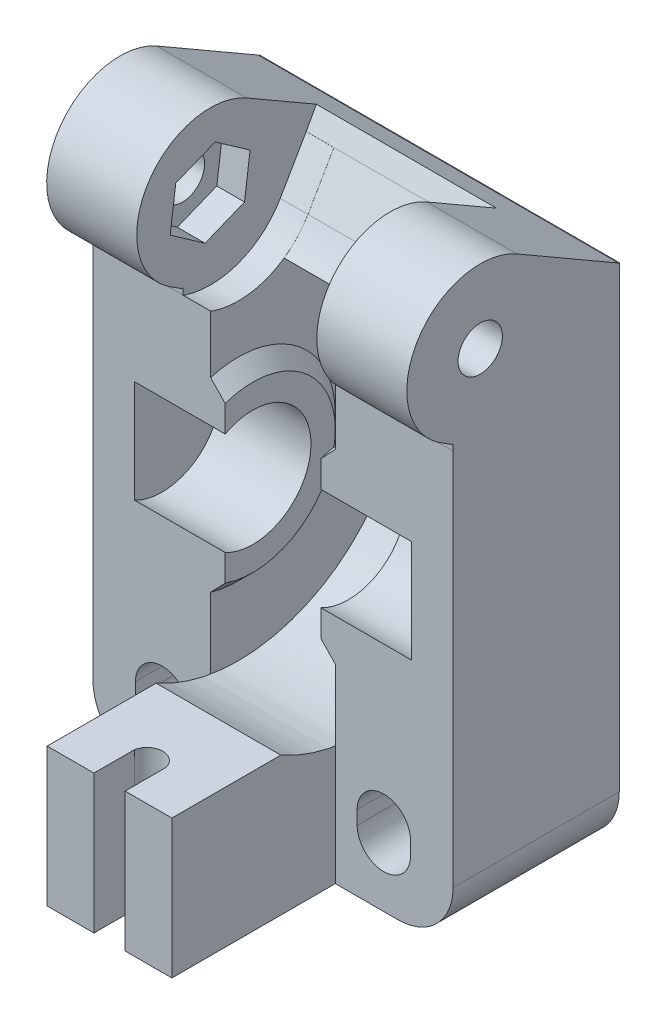
from build123d import *

# Parameters (mm, degrees)
BOSS_EXTRUDE1_DEPTH      = 4.5
BOSS_EXTRUDE2_DEPTH      = 8.5
BOSS_EXTRUDE6_DEPTH      = 6.5
BOSS_EXTRUDE4_DEPTH      = 1.05
BOSS_EXTRUDE8_REACH      = 49.945
CUT_EXTRUDE1_DEPTH       = 2
DRAFT1_ANGLE             = 44.789143365
M3_CLEARANCE_HOLE2_D     = 3.2
M8_CLEARANCE_HOLE1_D     = 8.407999997
M8_CLEARANCE_HOLE1_DEPTH = 6.549999998
BOSS_EXTRUDE5_DEPTH      = 4.5
CUT_EXTRUDE2_DEPTH       = 53.938496679
CUT_EXTRUDE3_DEPTH       = 35.848761309
FILLET1_R                = 4


with BuildPart() as part:
    # Sketch1 → Boss-Extrude1 (new body)
    with BuildSketch(Plane(origin=(-2, 0, 0), x_dir=(0, 0, -1), z_dir=(1, 0, 0))):
        with BuildLine():
            Line((-20.950248767, 5.007745307), (-22.824572843, 1.761345281))
            add(Edge.make_bspline(
                [(-22.824572843, 1.761345281), (-22.907235345, 1.63404528), (-22.989897847, 1.50674528), (-23.072560349, 1.379445279), (-23.090903988, 1.35119613), (-23.127591268, 1.294697832), (-23.187146413, 1.212723364), (-23.229540707, 1.160371306), (-23.250737854, 1.134195276), (-23.314414523, 1.055561942), (-23.378091191, 0.976928607), (-23.44176786, 0.898295272), (-23.462963255, 0.872121406), (-23.505354046, 0.819773673), (-23.573150965, 0.744483853), (-23.620785564, 0.696858132), (-23.644602863, 0.673045272), (-23.71614953, 0.60151194), (-23.787696196, 0.529978607), (-23.859242863, 0.458445275), (-23.883060949, 0.434631627), (-23.930697122, 0.387004333), (-24.005993759, 0.319211775), (-24.058341491, 0.276817446), (-24.084515357, 0.255620281), (-24.192798296, 0.167926271), (-24.301081235, 0.080232261), (-24.409364174, -0.007461749), (-24.415801672, -0.01267522), (-24.428676667, -0.023102162), (-24.448838233, -0.037748352), (-24.462734635, -0.046769251), (-24.469682836, -0.051279701), (-24.490556168, -0.0648297), (-24.511429499, -0.078379699), (-24.532302831, -0.091929698), (-24.535132328, -0.093766477), (-24.540791324, -0.097440034), (-24.537331747, -0.119297424), (-24.530814887, -0.121043793), (-24.527556458, -0.121916977), (-24.433502761, -0.147121213), (-24.339449064, -0.172325448), (-24.245395367, -0.197529683), (-24.221856021, -0.203837688), (-24.17477733, -0.216453699), (-24.105056076, -0.239110392), (-24.059554417, -0.25657939), (-24.036803587, -0.26531389), (-23.777816684, -0.364744152), (-23.51882978, -0.464174413), (-23.259842877, -0.563604675), (-23.19478657, -0.588581095), (-23.064673956, -0.638533935), (-22.87316776, -0.723799621), (-22.748984503, -0.787069656), (-22.686892875, -0.818704673), (-22.500366208, -0.913738006), (-22.31383954, -1.008771339), (-22.127312873, -1.103804671), (-22.065222187, -1.135439209), (-21.941040816, -1.198708283), (-21.75949603, -1.303520057), (-21.64261059, -1.379426466), (-21.584167871, -1.41737967), (-21.40859787, -1.531396336), (-21.233027869, -1.645413002), (-21.057457868, -1.759429668), (-20.999014093, -1.797383557), (-20.882126544, -1.873291336), (-20.712532127, -1.996511799), (-20.604220952, -2.084223711), (-20.550065365, -2.128079668), (-20.387373697, -2.259829668), (-20.224682029, -2.391579668), (-20.061990361, -2.523329668), (-20.007835687, -2.567184884), (-19.899526339, -2.654895317), (-19.743740529, -2.795161149), (-19.645187077, -2.893706834), (-19.595910351, -2.942979676), (-19.447882012, -3.090996348), (-19.299853674, -3.239013019), (-19.151825335, -3.387029691), (-19.102548454, -3.436302689), (-19.003994692, -3.534848683), (-18.8637252, -3.690633943), (-18.776019617, -3.798947782), (-18.732166825, -3.853104701), (-18.562645724, -4.06245832), (-18.393124622, -4.271811939), (-18.223603521, -4.481165558), (-18.204899229, -4.504264814), (-18.167490644, -4.550463326), (-18.114935909, -4.62279889), (-18.082558518, -4.672652768), (-18.066369822, -4.697579708), (-17.993420825, -4.809904707), (-17.920471827, -4.922229707), (-17.847522829, -5.034554707)],
                knots=[0, 0, 0, 0, 0.041251279, 0.041251279, 0.041251279, 0.050405353, 0.059559426, 0.068713499, 0.068713499, 0.068713499, 0.096212525, 0.096212525, 0.096212525, 0.105365842, 0.114519159, 0.123672476, 0.123672476, 0.123672476, 0.151168848, 0.151168848, 0.151168848, 0.160322467, 0.169476086, 0.178629706, 0.178629706, 0.178629706, 0.216498808, 0.216498808, 0.216498808, 0.218750153, 0.221001498, 0.223252843, 0.223252843, 0.223252843, 0.230016187, 0.230016187, 0.230016187, 0.230932996, 0.231849806, 0.232766615, 0.232766615, 0.232766615, 0.259230072, 0.259230072, 0.259230072, 0.26585323, 0.272476387, 0.279099545, 0.279099545, 0.279099545, 0.354495086, 0.354495086, 0.354495086, 0.373434095, 0.392373105, 0.411312114, 0.411312114, 0.411312114, 0.468205941, 0.468205941, 0.468205941, 0.487144663, 0.506083385, 0.525022107, 0.525022107, 0.525022107, 0.581916644, 0.581916644, 0.581916644, 0.600855708, 0.619794772, 0.638733836, 0.638733836, 0.638733836, 0.695629681, 0.695629681, 0.695629681, 0.714568425, 0.73350717, 0.752445914, 0.752445914, 0.752445914, 0.809338308, 0.809338308, 0.809338308, 0.828277112, 0.847215916, 0.86615472, 0.86615472, 0.86615472, 0.939366181, 0.939366181, 0.939366181, 0.947444046, 0.955521911, 0.963599776, 0.963599776, 0.963599776, 1, 1, 1, 1], degree=3))
            Line((-17.847522829, -5.034554707), (-17.847522829, 5.007745307))
            Line((-17.847522829, 5.007745307), (-20.950248767, 5.007745307))
        make_face()
    extrude(amount=-BOSS_EXTRUDE1_DEPTH)

    # Sketch2 → Boss-Extrude2 (add)
    with BuildSketch(Plane(origin=(-2, 0, 0), x_dir=(0, 0, -1), z_dir=(1, 0, 0))):
        with BuildLine():
            Line((-22.829111703, 1.761623143), (-20.95490634, 5.007745307))
            Line((-20.95490634, 5.007745307), (-17.852030403, 5.007745307))
            Line((-17.852030403, 5.007745307), (-17.852030403, -0.111212049))
            Line((-17.852030403, -0.111212049), (-17.852030403, -4.923501038))
            Line((-17.852030403, -4.923501038), (-17.852030403, -32.063654695))
            Line((-17.852030403, -32.063654695), (-29.85203041, -32.063654695))
            Line((-29.85203041, -32.063654695), (-29.85203041, -0.774730517))
            add(Edge.make_bspline(
                [(-22.829111703, 1.761623143), (-23.096003926, 1.350618607), (-23.105259907, 1.336579857), (-23.143132161, 1.279138172), (-23.177937749, 1.232622833), (-23.203882788, 1.197949025), (-23.256422161, 1.133070244), (-23.336169404, 1.034593545), (-23.415916644, 0.936116851), (-23.479442213, 0.857671652), (-23.495991929, 0.837891935), (-23.537737026, 0.787999464), (-23.580415171, 0.743194806), (-23.601442407, 0.721119852), (-23.633632993, 0.688859899), (-23.639069402, 0.683411774), (-23.687393882, 0.635097232), (-23.723238581, 0.599259904), (-23.759083401, 0.563422455), (-23.799641246, 0.522872951), (-23.8486953, 0.473828985), (-23.913675445, 0.408862202), (-23.939033317, 0.384925002), (-23.984140869, 0.342344596), (-24.034046523, 0.30086435), (-24.052549778, 0.285484939), (-24.132334682, 0.220871617), (-24.230809652, 0.14112226), (-24.329284638, 0.06137289), (-24.423419255, -0.014861459), (-24.427811691, -0.018315496), (-24.441004018, -0.028689417), (-24.453330993, -0.037147152), (-24.460538329, -0.042092222), (-24.479785949, -0.054586621), (-24.514040982, -0.076822931), (-24.532929494, -0.089084218), (-24.56816545, -0.111957283), (-24.745486074, -0.227101714), (-24.812268152, -0.27046714), (-24.851762615, -0.296113155), (-24.888938105, -0.320253329), (-24.905070689, -0.330358389), (-24.932894435, -0.347786512), (-24.959534352, -0.362823053), (-24.999265551, -0.385248791), (-25.071629076, -0.422181378), (-25.077196477, -0.425022845), (-25.184527295, -0.479725674), (-25.393133241, -0.586044956), (-25.410410472, -0.594652958), (-25.470854029, -0.624767637), (-25.525526298, -0.647941663), (-25.544497996, -0.655983228), (-25.564619768, -0.664037911), (-25.588245862, -0.673495363), (-25.643368258, -0.694648168), (-25.761673891, -0.740047063), (-25.879979522, -0.785445958), (-25.971893198, -0.820717139), (-25.998492416, -0.830344041), (-26.058872279, -0.852196978), (-26.119103259, -0.869689652), (-26.148455957, -0.878214454), (-26.207080202, -0.893929356), (-26.234483588, -0.901275148), (-26.265830333, -0.909678003), (-26.294123823, -0.917262398), (-26.363747219, -0.935925749), (-26.442682133, -0.95708516), (-26.486143326, -0.968735432), (-26.545375218, -0.984613221), (-26.567826392, -0.990319391), (-26.590101476, -0.995980806), (-26.608888839, -1.000364869), (-26.668323645, -1.014234083), (-26.73329044, -1.025198822), (-26.754575097, -1.02879113), (-26.858421317, -1.045225248), (-27.104809922, -1.084217321), (-27.108741149, -1.084837562), (-27.186274438, -1.097070211), (-27.234308252, -1.102400585), (-27.289807993, -1.108559462), (-27.360727376, -1.11251747), (-27.373321483, -1.113220346), (-27.613813132, -1.125832465), (-27.727437751, -1.131791288), (-27.740360834, -1.132414529), (-27.811428265, -1.135841896), (-27.867154018, -1.135391855), (-27.915100748, -1.135004638), (-27.993859388, -1.130890518), (-27.997521971, -1.130699195), (-28.120402784, -1.124252996), (-28.351625626, -1.112123287), (-28.373482727, -1.11072178), (-28.439741214, -1.106473196), (-28.499781883, -1.098829458), (-28.519772912, -1.096284414), (-28.541659028, -1.093077128), (-28.564265945, -1.089764213), (-28.625146204, -1.080127958), (-28.750307822, -1.060317115), (-28.875464624, -1.040507035), (-28.97013711, -1.025522075), (-29.00053164, -1.019996266), (-29.062842244, -1.008668027), (-29.124551422, -0.993269048), (-29.151678629, -0.986499693), (-29.271563905, -0.954360042), (-29.318142297, -0.941872994), (-29.369480172, -0.928109991), (-29.606745785, -0.86450223), (-29.614249121, -0.86239452), (-29.645000159, -0.853756458), (-29.674540935, -0.842753836), (-29.682170665, -0.839912101), (-29.733724588, -0.820128919), (-29.805071459, -0.792750436), (-29.85203041, -0.774730517)],
                knots=[0, 0, 0, 0.0625, 0.0625, 0.078125, 0.078125, 0.09375, 0.09375, 0.125, 0.125, 0.140625, 0.140625, 0.15625, 0.15625, 0.165625, 0.165625, 0.175, 0.175, 0.1875, 0.1875, 0.203125, 0.203125, 0.21875, 0.21875, 0.234375, 0.234375, 0.25, 0.25, 0.28125, 0.28125, 0.296875, 0.296875, 0.30078125, 0.30078125, 0.3046875, 0.3046875, 0.3125, 0.3125, 0.34375, 0.34375, 0.359375, 0.359375, 0.3671875, 0.3671875, 0.375, 0.375, 0.390625, 0.390625, 0.40625, 0.40625, 0.4375, 0.4375, 0.453125, 0.453125, 0.458333333, 0.458333333, 0.46875, 0.46875, 0.5, 0.5, 0.515625, 0.515625, 0.53125, 0.53125, 0.5425, 0.5425, 0.55, 0.55, 0.5625, 0.5625, 0.578125, 0.578125, 0.588541667, 0.588541667, 0.59375, 0.59375, 0.609375, 0.609375, 0.625, 0.625, 0.65625, 0.65625, 0.671875, 0.671875, 0.6875, 0.6875, 0.71875, 0.71875, 0.734375, 0.734375, 0.75, 0.75, 0.765625, 0.765625, 0.78125, 0.78125, 0.8125, 0.8125, 0.828125, 0.828125, 0.833333333, 0.833333333, 0.84375, 0.84375, 0.875, 0.875, 0.890625, 0.890625, 0.90625, 0.90625, 0.925, 0.925, 0.9375, 0.9375, 0.96875, 0.96875, 0.9765625, 0.9765625, 0.984375, 0.984375, 1, 1, 1], degree=2))
        make_face()
    extrude(amount=BOSS_EXTRUDE2_DEPTH)

    # Sketch3 → Boss-Extrude6 (add)
    with BuildSketch(Plane(origin=(6.5, 0, 0), x_dir=(0, 0, -1), z_dir=(1, 0, 0))):
        with BuildLine():
            Line((-25.239838693, 9.247199614), (-17.896884563, 5.007745307))
            Line((-17.896884563, 5.007745307), (-17.852010829, 5.007745307))
            Line((-17.852010829, 5.007745307), (-17.852010829, -1.344758893))
            Line((-17.852010829, -1.344758893), (-29.852010838, -1.344758893))
            Line((-29.852010838, -1.344758893), (-29.852010838, -0.304054689))
            Line((-29.852010838, -0.304054689), (-29.96846684, -0.304054689))
            Line((-29.96846684, -0.304054689), (-31.011810834, 0.373345316))
            ThreePointArc((-31.011810834, 0.373345316), (-32.333230452, 7.546966984), (-25.239838693, 9.247199614))
        make_face()
    extrude(amount=-BOSS_EXTRUDE6_DEPTH)

    # Sketch4 → Boss-Extrude4 (add)
    with BuildSketch(Plane.ZY.offset(2)):
        with BuildLine():
            Line((29.85203041, -4.925086097), (29.85203041, -18.344370525))
            ThreePointArc((29.85203041, -18.344370525), (20.863574404, -11.634728311), (29.85203041, -4.925086097))
        make_face()
    extrude(amount=BOSS_EXTRUDE4_DEPTH)

    # Boss-Extrude8: up to this face of the body (flat: up to its plane)
    boss_extrude8_end = Plane(part.part.faces().sort_by_distance((0, 4.353857774, 26.912285138))[0])
    # Sketch19 → Boss-Extrude8 (add, up to the picked face)
    with BuildSketch(Plane.ZY.offset(6.5), mode=Mode.PRIVATE) as boss_extrude8_sk1:
        Polygon((20.950248767, 5.007745307), (20.223029104, 6.350744776), (17.896884563, 5.007745307), align=None)
    boss_extrude8_tool1 = split(extrude(boss_extrude8_sk1.sketch, amount=-BOSS_EXTRUDE8_REACH, mode=Mode.PRIVATE), bisect_by=boss_extrude8_end, keep=Keep.BOTH, mode=Mode.PRIVATE)
    add(boss_extrude8_tool1.solids().sort_by(Axis((-6.5, 5.455412, 19.690054), (1, 0, 0)))[0])

    # Sketch5 → Cut-Extrude1 (cut)
    with BuildSketch(Plane.ZY):
        Polygon((28.257066357, 1.674406753), (30.773684802, 3.439216401), (30.372420283, 6.486659309), (27.523019445, 7.639410955), (25.006401, 5.874601306), (25.407665519, 2.827158399), align=None)
    extrude(amount=-CUT_EXTRUDE1_DEPTH, mode=Mode.SUBTRACT)

    # Draft1
    draft1_faces = [part.faces().sort_by_distance(p)[0] for p in [
        (-2.525, -11.634728311, 20.863574404),
    ]]
    draft(draft1_faces, Plane(origin=(-2, -0.785445958, 25.879979522), x_dir=(0, 0, -1), z_dir=(-1, 0, 0)), DRAFT1_ANGLE)

    # M3 Clearance Hole2 (through all)
    with Locations(Plane.ZY.offset(-2)):
        with Locations((27.890042901, 4.656908854)):
            Hole(M3_CLEARANCE_HOLE2_D / 2)

    # M8 Clearance Hole1
    with Locations(Plane.ZY.offset(3.05)):
        with Locations((27.862086714, -11.634728311)):
            Hole(M8_CLEARANCE_HOLE1_D / 2, depth=M8_CLEARANCE_HOLE1_DEPTH)

    # Sketch10 → Boss-Extrude5 (add)
    with BuildSketch(Plane.ZY.offset(2)):
        with BuildLine():
            Line((33.787830403, -22.063654664), (41.652030403, -22.063654664))
            Line((41.652030403, -22.063654664), (41.652030403, -32.063654695))
            Line((41.652030403, -32.063654695), (17.852030403, -32.063654695))
            Line((17.852030403, -32.063654695), (17.852030403, -18.242754699))
            add(Edge.make_bspline(
                [(33.787830403, -22.063654664), (33.5240804, -22.198029666), (33.260330396, -22.332404668), (32.996580392, -22.466779671), (32.936269232, -22.49750692), (32.815646914, -22.558961419), (32.629251216, -22.64092215), (32.502870659, -22.689443836), (32.43968038, -22.713704678), (32.244247042, -22.788738015), (32.048813703, -22.863771352), (31.853380365, -22.938804689), (31.788324108, -22.963781943), (31.658211595, -23.01373645), (31.458840856, -23.0785217), (31.324217196, -23.114593697), (31.256905365, -23.132629695), (30.993913548, -23.203097545), (30.73092173, -23.273565395), (30.467929913, -23.344033245), (30.441077957, -23.351228144), (30.387374046, -23.365617942), (30.305575755, -23.383005925), (30.25066218, -23.391705105), (30.223205393, -23.396054695), (30.140722062, -23.409121362), (30.05823873, -23.422188028), (29.975755399, -23.435254695), (29.94129442, -23.44071386), (29.872372462, -23.45163219), (29.768988996, -23.468006351), (29.7000666, -23.478921914), (29.665605402, -23.484379695), (29.541322068, -23.504063028), (29.417038735, -23.523746362), (29.292755402, -23.543429695), (29.237652519, -23.552156596), (29.127446755, -23.569610399), (28.95989526, -23.58062494), (28.848468688, -23.586461443), (28.792755402, -23.589379695), (28.583705402, -23.600329695), (28.374655402, -23.611279695), (28.165605402, -23.622229695), (28.096016356, -23.625874756), (27.956838264, -23.633164879), (27.747212558, -23.633164531), (27.608034454, -23.62587464), (27.538445402, -23.622229695), (27.329388735, -23.611279695), (27.120332068, -23.600329695), (26.911275402, -23.589379695), (26.841685245, -23.585734692), (26.702504932, -23.578444685), (26.494023007, -23.556534702), (26.356367937, -23.534731364), (26.287540402, -23.523829695), (26.080773735, -23.491079695), (25.874007068, -23.458329695), (25.667240402, -23.425579695), (25.598412752, -23.414678008), (25.460757452, -23.392874633), (25.255708627, -23.349288865), (25.121086477, -23.313216085), (25.053775402, -23.295179695), (24.851565402, -23.240996362), (24.649355402, -23.186813028), (24.447145402, -23.132629695), (24.379833719, -23.114593142), (24.245210353, -23.078520036), (24.045840019, -23.013734223), (23.915726933, -22.963781201), (23.85067039, -22.938804689), (23.655230381, -22.863771352), (23.459790373, -22.788738015), (23.264350365, -22.713704678), (23.199294057, -22.688728257), (23.069181441, -22.638775416), (22.877675241, -22.553509727), (22.753491983, -22.49023969), (22.691400354, -22.458604672), (22.504873688, -22.363571338), (22.318347022, -22.268538004), (22.131820357, -22.17350467), (22.069729671, -22.141870132), (21.945548301, -22.078601057), (21.764003517, -21.973789281), (21.647118078, -21.897882872), (21.588675359, -21.859929668), (21.41310536, -21.745913001), (21.237535361, -21.631896333), (21.061965361, -21.517879666), (21.003521587, -21.479925777), (20.886634039, -21.404017997), (20.717039624, -21.280797533), (20.60872845, -21.193085621), (20.554572863, -21.149229664), (20.391881197, -21.017479664), (20.229189531, -20.885729663), (20.066497865, -20.753979662), (20.012343194, -20.710124448), (19.904033853, -20.622414019), (19.74824805, -20.482148195), (19.649694604, -20.383602516), (19.60041788, -20.334329676), (19.452389557, -20.18631302), (19.304361233, -20.038296363), (19.156332909, -19.890279706), (19.10705603, -19.841006711), (19.008502272, -19.742460721), (18.868232788, -19.586675466), (18.780527208, -19.478361632), (18.736674418, -19.424204714), (18.567153313, -19.214851091), (18.397632208, -19.005497468), (18.228111103, -18.796143845), (18.209406811, -18.773044589), (18.171998226, -18.726846077), (18.11944349, -18.654510513), (18.087066098, -18.604656635), (18.070877402, -18.579729696), (17.997928402, -18.467404697), (17.924979402, -18.355079698), (17.852030403, -18.242754699)],
                knots=[0, 0, 0, 0, 0.049231277, 0.049231277, 0.049231277, 0.06048889, 0.071746503, 0.083004115, 0.083004115, 0.083004115, 0.117821383, 0.117821383, 0.117821383, 0.129411428, 0.141001472, 0.152591517, 0.152591517, 0.152591517, 0.197874595, 0.197874595, 0.197874595, 0.202498082, 0.207121569, 0.211745056, 0.211745056, 0.211745056, 0.225634539, 0.225634539, 0.225634539, 0.231437472, 0.237240404, 0.243043337, 0.243043337, 0.243043337, 0.263971448, 0.263971448, 0.263971448, 0.273250241, 0.282529033, 0.291807826, 0.291807826, 0.291807826, 0.326624146, 0.326624146, 0.326624146, 0.338213882, 0.349803619, 0.361393356, 0.361393356, 0.361393356, 0.396210783, 0.396210783, 0.396210783, 0.407800704, 0.419390624, 0.430980545, 0.430980545, 0.430980545, 0.46579814, 0.46579814, 0.46579814, 0.477388081, 0.488978021, 0.500567961, 0.500567961, 0.500567961, 0.535385437, 0.535385437, 0.535385437, 0.546975482, 0.558565527, 0.570155572, 0.570155572, 0.570155572, 0.604973875, 0.604973875, 0.604973875, 0.616563878, 0.628153881, 0.639743884, 0.639743884, 0.639743884, 0.674560889, 0.674560889, 0.674560889, 0.686150716, 0.697740542, 0.709330369, 0.709330369, 0.709330369, 0.744147809, 0.744147809, 0.744147809, 0.755737845, 0.767327881, 0.778917917, 0.778917917, 0.778917917, 0.813736157, 0.813736157, 0.813736157, 0.825325997, 0.836915837, 0.848505677, 0.848505677, 0.848505677, 0.883321802, 0.883321802, 0.883321802, 0.894911678, 0.906501555, 0.918091431, 0.918091431, 0.918091431, 0.962894251, 0.962894251, 0.962894251, 0.967837619, 0.972780986, 0.977724353, 0.977724353, 0.977724353, 1, 1, 1, 1], degree=3))
        make_face()
    extrude(amount=BOSS_EXTRUDE5_DEPTH)

    # Sketch11 → Cut-Extrude2 (cut, through all)
    with BuildSketch(Plane(origin=(0, -22.063654664, 0), x_dir=(1, 0, 0), z_dir=(0, 1, 0))):
        with BuildLine():
            Line((-5.375, -41.652030403), (-6.5, -41.652030403))
            Line((-6.5, -41.652030403), (-6.5, -37.801320568))
            ThreePointArc((-6.5, -37.801320568), (-5.775377606, -38.05849236), (-5.375, -38.714931784))
            Line((-5.375, -38.714931784), (-5.375, -41.652030403))
        make_face()
    extrude(amount=-CUT_EXTRUDE2_DEPTH, mode=Mode.SUBTRACT)

    # Sketch12 → Cut-Extrude3 (cut, through all)
    with BuildSketch(Plane.XY.offset(29.85203041)):
        with BuildLine():
            Line((-0.42499996, -26.638654685), (-0.42499996, -27.638654684))
            ThreePointArc((-0.42499996, -27.638654684), (1.50000004, -29.563654684), (3.42500004, -27.638654684))
            Line((3.42500004, -27.638654684), (3.42500004, -26.638654685))
            ThreePointArc((3.42500004, -26.638654685), (1.50000004, -24.713654685), (-0.42499996, -26.638654685))
        make_face()
    extrude(amount=-CUT_EXTRUDE3_DEPTH, mode=Mode.SUBTRACT)

    # Fillet1
    fillet1_edges = [part.edges().sort_by_distance(p)[0] for p in [
        (6.5, -32.063654695, 23.852030406),
    ]]
    fillet(fillet1_edges, radius=FILLET1_R)

    # Mirror2: part across plane


with BuildPart() as part_1:
    add(part.part)
    add(part.part.mirror(Plane(origin=(-6.5, -23.297831088, 25.063671125), x_dir=(0, 0, 1), z_dir=(-1, 0, 0))))


solid = part_1.part
